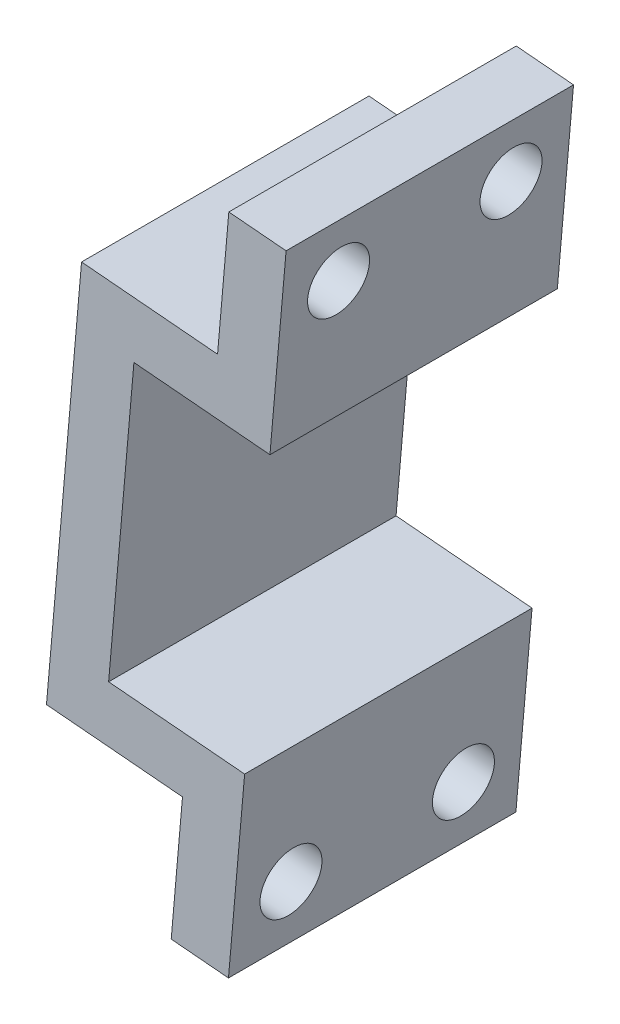
from build123d import *

# Parameters (mm, degrees)
BOSS_EXTRUDE1_DEPTH = 20
SKETCH2_R           = 2.15
CUT_EXTRUDE1_DEPTH  = 5


with BuildPart() as part:
    # Sketch1 → Boss-Extrude1 (new body)
    with BuildSketch(Plane.XY):
        Polygon((-80.653583913, 18.961055491), (-76.668805121, 18.61243252), (-77.793114202, 5.761520915), (-87.256963834, 6.589500471), (-89.017509838, -13.533632431), (-79.553660206, -14.361611987), (-80.677969287, -27.212523592), (-84.662748079, -26.863900621), (-83.878346395, -17.898148338), (-93.342196027, -17.070168782), (-90.90183523, 10.823282764), (-81.437985598, 9.995303208), align=None)
    extrude(amount=-BOSS_EXTRUDE1_DEPTH)

    # Sketch2 → Cut-Extrude1 (cut)
    with BuildSketch(Plane(origin=(-81.687205696, 7.146704453, 0), x_dir=(0, 0, 1), z_dir=(-0.996194698, 0.087155743, 0))):
        with Locations((-4, -30.140520061)):
            Circle(SKETCH2_R)
        with Locations((-16, -30.140520061)):
            Circle(SKETCH2_R)
        with Locations((-4, 7.859479939)):
            Circle(SKETCH2_R)
        with Locations((-16, 7.859479939)):
            Circle(SKETCH2_R)
    extrude(amount=-CUT_EXTRUDE1_DEPTH, mode=Mode.SUBTRACT)


solid = part.part
